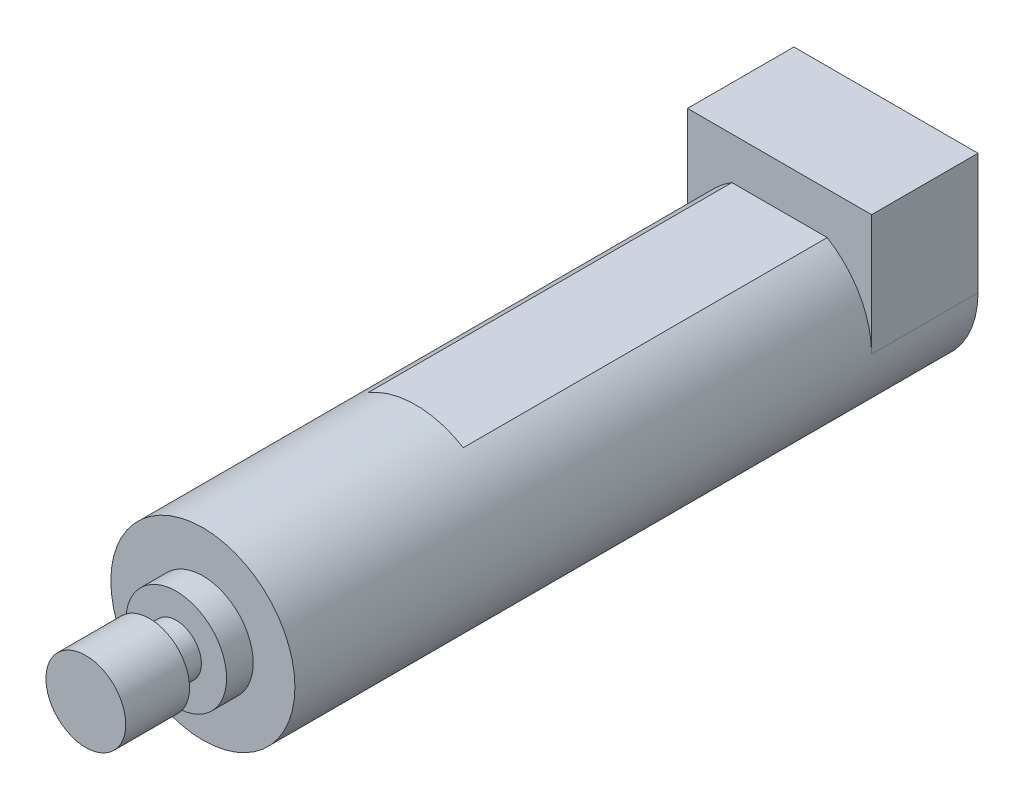
from build123d import *

# Parameters (mm, degrees)
BOSS_EXTRUDE1_DEPTH = 12.7
BOSS_EXTRUDE2_DEPTH = 43.434
SKETCH3_R           = 10.9855
BOSS_EXTRUDE3_DEPTH = 25.4
SKETCH4_R           = 6.0071
BOSS_EXTRUDE4_DEPTH = 3.175
SKETCH5_R           = 2.9972
BOSS_EXTRUDE5_DEPTH = 3.175
SKETCH6_R           = 4.7625
BOSS_EXTRUDE6_DEPTH = 7.62


with BuildPart() as part:
    # Sketch1 → Boss-Extrude1 (new body)
    with BuildSketch(Plane.XY):
        with BuildLine():
            Line((-10.9855, 0), (-10.9855, 14.4145))
            Line((-10.9855, 14.4145), (10.9855, 14.4145))
            Line((10.9855, 14.4145), (10.9855, 0))
            ThreePointArc((10.9855, 0), (0, -10.9855), (-10.9855, 0))
        make_face()
    extrude(amount=BOSS_EXTRUDE1_DEPTH)

    # Sketch2 → Boss-Extrude2 (add)
    with BuildSketch(Plane.XY.offset(12.7)):
        with BuildLine():
            Line((-5.68848, 9.398), (5.68848, 9.398))
            ThreePointArc((5.68848, 9.398), (10.9855, 0), (5.68848, -9.398))
            Line((5.68848, -9.398), (-5.68848, -9.398))
            ThreePointArc((-5.68848, -9.398), (-10.9855, 0), (-5.68848, 9.398))
        make_face()
    extrude(amount=BOSS_EXTRUDE2_DEPTH)

    # Sketch3 → Boss-Extrude3 (add)
    with BuildSketch(Plane.XY.offset(56.134)):
        Circle(SKETCH3_R)
    extrude(amount=BOSS_EXTRUDE3_DEPTH)

    # Sketch4 → Boss-Extrude4 (add)
    with BuildSketch(Plane.XY.offset(81.534)):
        Circle(SKETCH4_R)
    extrude(amount=BOSS_EXTRUDE4_DEPTH)

    # Sketch5 → Boss-Extrude5 (add)
    with BuildSketch(Plane.XY.offset(84.709)):
        Circle(SKETCH5_R)
    extrude(amount=BOSS_EXTRUDE5_DEPTH)

    # Sketch6 → Boss-Extrude6 (add)
    with BuildSketch(Plane.XY.offset(87.884)):
        Circle(SKETCH6_R)
    extrude(amount=BOSS_EXTRUDE6_DEPTH)


solid = part.part
